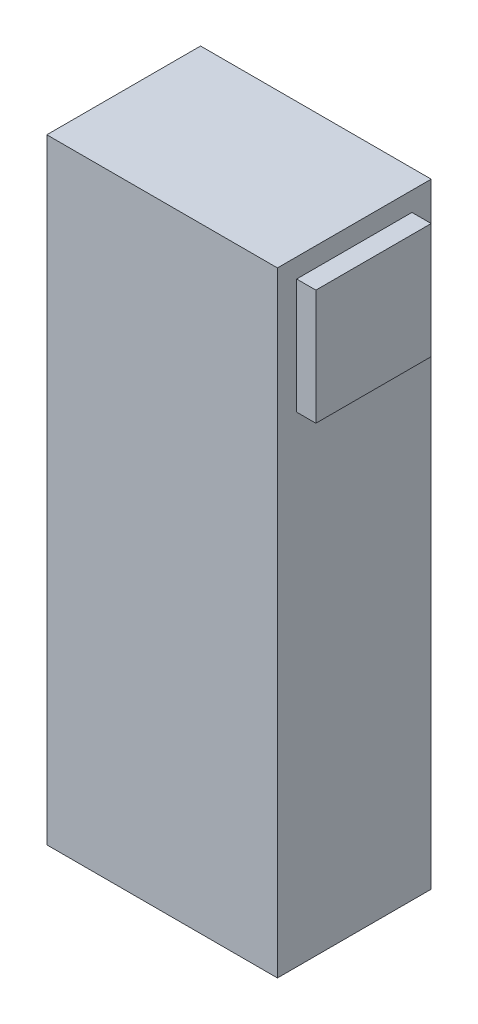
from build123d import *

# Parameters (mm, degrees)
SKETCH1_W           = 38.1
SKETCH1_H           = 25.4
BOSS_EXTRUDE1_DEPTH = 101.6
SKETCH2_W           = 19.05
SKETCH2_H           = 19.05
BOSS_EXTRUDE2_DEPTH = 3.175


with BuildPart() as part:
    # Sketch1 → Boss-Extrude1 (new body)
    with BuildSketch(Plane(origin=(0, 0, 0), x_dir=(1, 0, 0), z_dir=(0, 1, 0))):
        with Locations((19.05, 12.7)):
            Rectangle(SKETCH1_W, SKETCH1_H)
    extrude(amount=BOSS_EXTRUDE1_DEPTH)

    # Sketch2 → Boss-Extrude2 (add)
    with BuildSketch(Plane(origin=(38.1, 0, 0), x_dir=(0, 0, -1), z_dir=(1, 0, 0))):
        with Locations((12.7, 88.9)):
            Rectangle(SKETCH2_W, SKETCH2_H)
    extrude(amount=BOSS_EXTRUDE2_DEPTH)


solid = part.part
